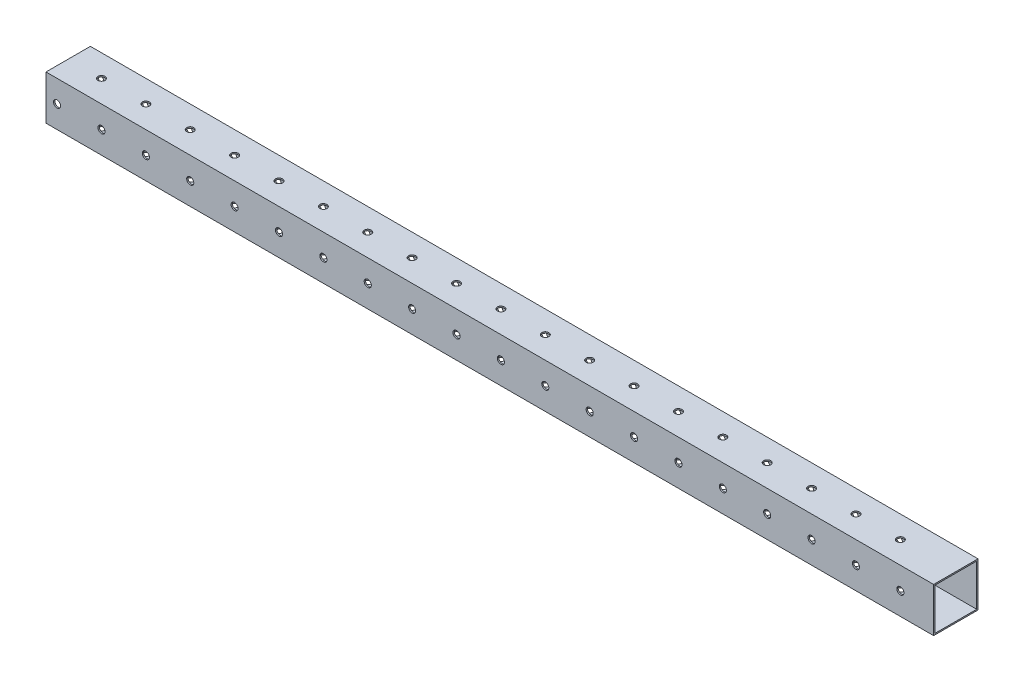
from build123d import *

# Parameters (mm, degrees)
SKETCH1_W           = 25.4
SKETCH1_H           = 25.4
SKETCH1_W_2         = 23.876
SKETCH1_H_2         = 23.876
EXTRUDE_THIN1_DEPTH = 508
SKETCH2_R           = 2.032
CUT_EXTRUDE1_DEPTH  = 26.4
SKETCH3_R           = 2.032
CUT_EXTRUDE2_DEPTH  = 26.4


with BuildPart() as part:
    # Sketch1 → Extrude-Thin1 (new body)
    with BuildSketch(Plane(origin=(0, 0, 0), x_dir=(0, 0, -1), z_dir=(1, 0, 0))):
        with Locations((12.7, 12.7)):
            Rectangle(SKETCH1_W, SKETCH1_H)
        with Locations((12.7, 12.7)):
            Rectangle(SKETCH1_W_2, SKETCH1_H_2, mode=Mode.SUBTRACT)
    extrude(amount=EXTRUDE_THIN1_DEPTH)

    # Sketch2 → Cut-Extrude1 (cut, through all)
    with BuildSketch(Plane(origin=(0, 0, -25.4), x_dir=(-1, 0, 0), z_dir=(0, 0, -1))):
        with Locations((-6.35, 12.7)):
            Circle(SKETCH2_R)
        with Locations((-31.75, 12.7)):
            Circle(SKETCH2_R)
        with Locations((-57.15, 12.7)):
            Circle(SKETCH2_R)
        with Locations((-82.55, 12.7)):
            Circle(SKETCH2_R)
        with Locations((-107.95, 12.7)):
            Circle(SKETCH2_R)
        with Locations((-133.35, 12.7)):
            Circle(SKETCH2_R)
        with Locations((-158.75, 12.7)):
            Circle(SKETCH2_R)
        with Locations((-184.15, 12.7)):
            Circle(SKETCH2_R)
        with Locations((-209.55, 12.7)):
            Circle(SKETCH2_R)
        with Locations((-234.95, 12.7)):
            Circle(SKETCH2_R)
        with Locations((-260.35, 12.7)):
            Circle(SKETCH2_R)
        with Locations((-285.75, 12.7)):
            Circle(SKETCH2_R)
        with Locations((-311.15, 12.7)):
            Circle(SKETCH2_R)
        with Locations((-336.55, 12.7)):
            Circle(SKETCH2_R)
        with Locations((-361.95, 12.7)):
            Circle(SKETCH2_R)
        with Locations((-387.35, 12.7)):
            Circle(SKETCH2_R)
        with Locations((-412.75, 12.7)):
            Circle(SKETCH2_R)
        with Locations((-438.15, 12.7)):
            Circle(SKETCH2_R)
        with Locations((-463.55, 12.7)):
            Circle(SKETCH2_R)
        with Locations((-488.95, 12.7)):
            Circle(SKETCH2_R)
    extrude(amount=-CUT_EXTRUDE1_DEPTH, mode=Mode.SUBTRACT)

    # Sketch3 → Cut-Extrude2 (cut, through all)
    with BuildSketch(Plane(origin=(0, 25.4, 0), x_dir=(1, 0, 0), z_dir=(0, 1, 0))):
        with Locations((476.25, 12.7)):
            Circle(SKETCH3_R)
        with Locations((450.85, 12.7)):
            Circle(SKETCH3_R)
        with Locations((425.45, 12.7)):
            Circle(SKETCH3_R)
        with Locations((400.05, 12.7)):
            Circle(SKETCH3_R)
        with Locations((374.65, 12.7)):
            Circle(SKETCH3_R)
        with Locations((349.25, 12.7)):
            Circle(SKETCH3_R)
        with Locations((323.85, 12.7)):
            Circle(SKETCH3_R)
        with Locations((298.45, 12.7)):
            Circle(SKETCH3_R)
        with Locations((273.05, 12.7)):
            Circle(SKETCH3_R)
        with Locations((247.65, 12.7)):
            Circle(SKETCH3_R)
        with Locations((222.25, 12.7)):
            Circle(SKETCH3_R)
        with Locations((196.85, 12.7)):
            Circle(SKETCH3_R)
        with Locations((171.45, 12.7)):
            Circle(SKETCH3_R)
        with Locations((146.05, 12.7)):
            Circle(SKETCH3_R)
        with Locations((120.65, 12.7)):
            Circle(SKETCH3_R)
        with Locations((95.25, 12.7)):
            Circle(SKETCH3_R)
        with Locations((69.85, 12.7)):
            Circle(SKETCH3_R)
        with Locations((44.45, 12.7)):
            Circle(SKETCH3_R)
        with Locations((19.05, 12.7)):
            Circle(SKETCH3_R)
    extrude(amount=-CUT_EXTRUDE2_DEPTH, mode=Mode.SUBTRACT)


solid = part.part
